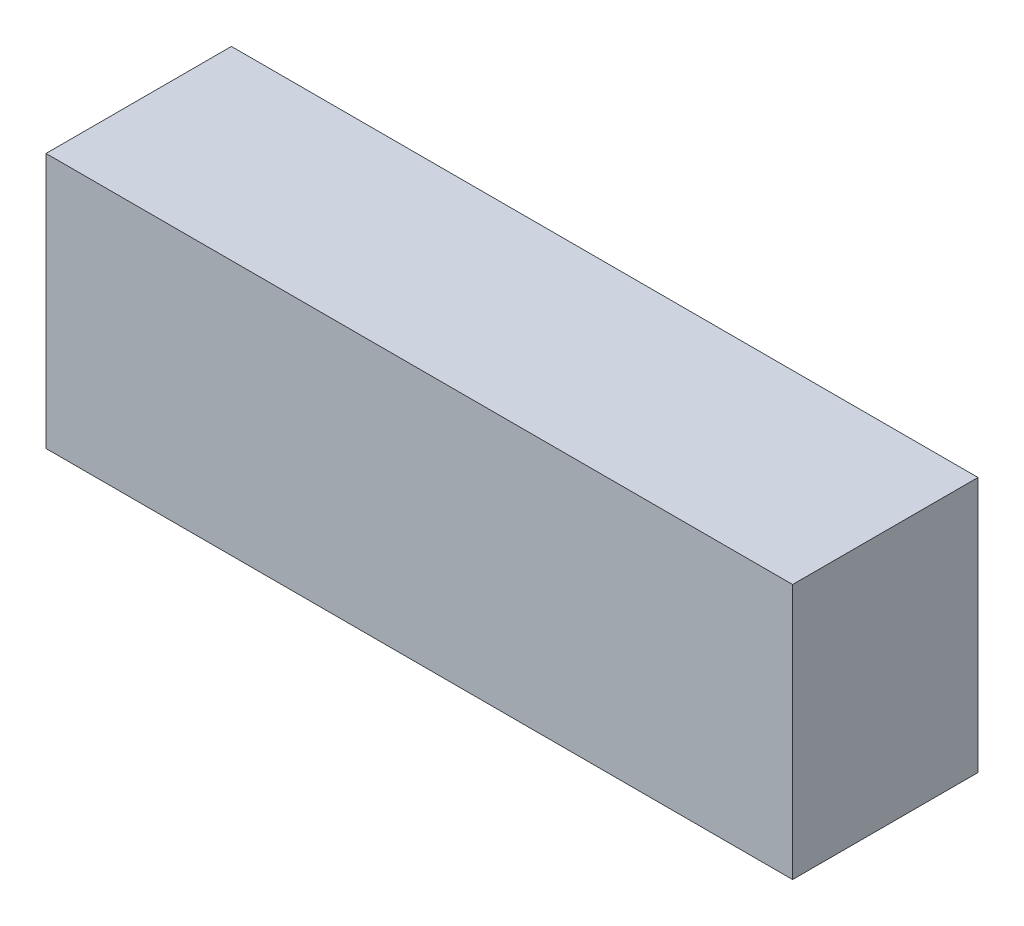
from build123d import *

# Parameters (mm, degrees)
SKETCH1_W           = 149
SKETCH1_H           = 37
BOSS_EXTRUDE1_DEPTH = 51


with BuildPart() as part:
    # Sketch1 → Boss-Extrude1 (new body)
    with BuildSketch(Plane(origin=(0, 0, 0), x_dir=(1, 0, 0), z_dir=(0, 1, 0))):
        with Locations((74.5, 18.5)):
            Rectangle(SKETCH1_W, SKETCH1_H)
    extrude(amount=BOSS_EXTRUDE1_DEPTH)


solid = part.part
